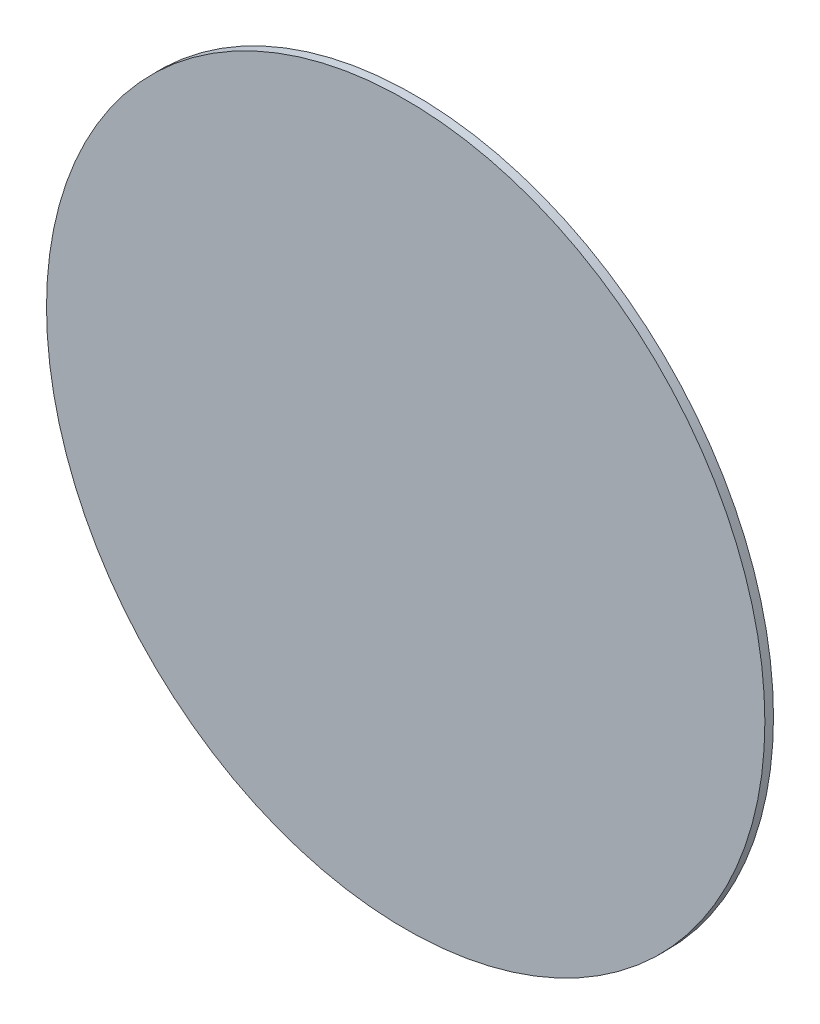
from build123d import *

# Parameters (mm, degrees)
SKETCH1_R           = 125
BOSS_EXTRUDE1_DEPTH = 3


with BuildPart() as part:
    # Sketch1 → Boss-Extrude1 (new body)
    with BuildSketch(Plane.XY):
        Circle(SKETCH1_R)
    extrude(amount=BOSS_EXTRUDE1_DEPTH)


solid = part.part
